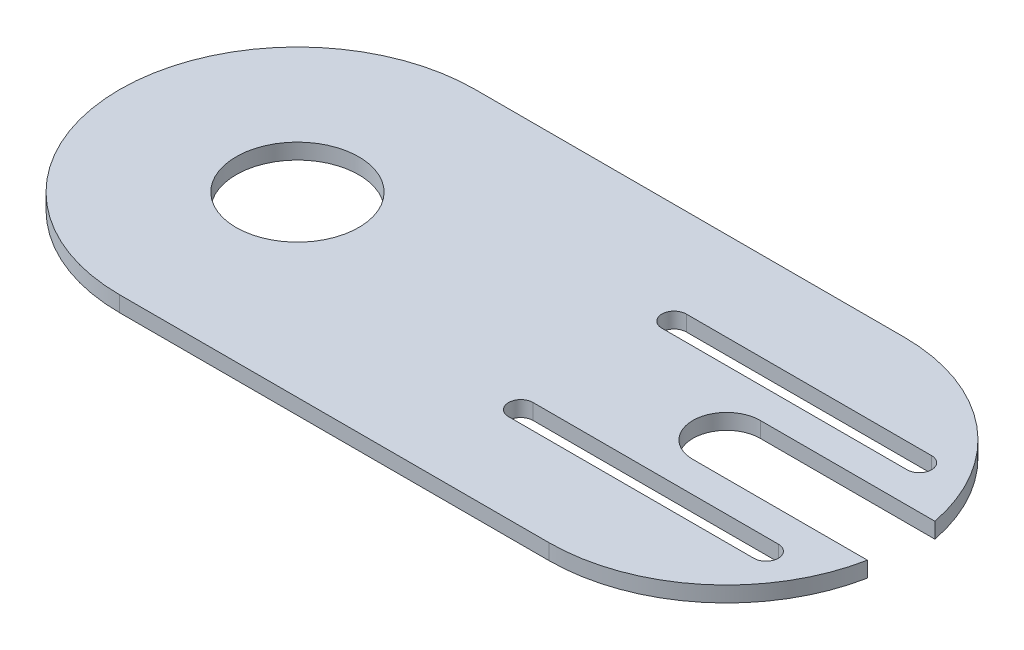
from build123d import *

# Parameters (mm, degrees)
SKETCH1_R           = 29
SKETCH1_R_2         = 10
BOSS_EXTRUDE1_DEPTH = 2.54


with BuildPart() as part:
    # Sketch1 → Boss-Extrude1 (new body)
    with BuildSketch(Plane(origin=(0, 0, 0), x_dir=(1, 0, 0), z_dir=(0, 1, 0))):
        Circle(SKETCH1_R)
        Circle(SKETCH1_R_2, mode=Mode.SUBTRACT)
        with BuildLine():
            Line((70, 29), (0, 29))
            ThreePointArc((0, 29), (20.506096654, 20.506096654), (29, 0))
            ThreePointArc((29, 0), (20.506096654, -20.506096654), (0, -29))
            Line((0, -29), (70, -29))
            ThreePointArc((70, -29), (88.459414942, -22.366269246), (98.47367205, -5.5))
            Line((98.47367205, -5.5), (70, -5.5))
            ThreePointArc((70, -5.5), (64.5, 0), (70, 5.5))
            Line((70, 5.5), (98.47367205, 5.5))
            ThreePointArc((98.47367205, 5.5), (88.459414942, 22.366269246), (70, 29))
        make_face()
        with BuildLine():
            Line((88.940140067, -14.5), (48.940140067, -14.5))
            ThreePointArc((48.940140067, -14.5), (46.940140067, -12.5), (48.940140067, -10.5))
            Line((48.940140067, -10.5), (88.940140067, -10.5))
            ThreePointArc((88.940140067, -10.5), (90.354353629, -11.085786438), (90.940140067, -12.5))
            ThreePointArc((90.940140067, -12.5), (90.354353629, -13.914213562), (88.940140067, -14.5))
        make_face(mode=Mode.SUBTRACT)
        with BuildLine():
            Line((88.940140067, 10.5), (48.940140067, 10.5))
            ThreePointArc((48.940140067, 10.5), (46.940140067, 12.5), (48.940140067, 14.5))
            Line((48.940140067, 14.5), (88.940140067, 14.5))
            ThreePointArc((88.940140067, 14.5), (90.354353629, 13.914213562), (90.940140067, 12.5))
            ThreePointArc((90.940140067, 12.5), (90.354353629, 11.085786438), (88.940140067, 10.5))
        make_face(mode=Mode.SUBTRACT)
    extrude(amount=BOSS_EXTRUDE1_DEPTH)


solid = part.part
